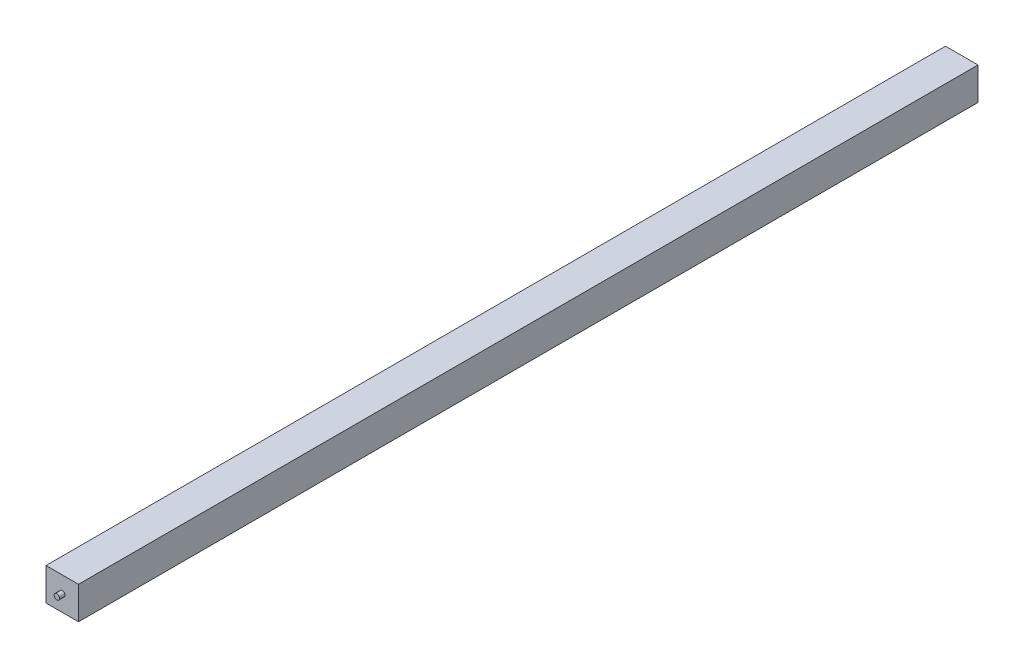
from build123d import *

# Parameters (mm, degrees)
SKETCH1_W           = 830
SKETCH1_H           = 30
BOSS_EXTRUDE1_DEPTH = 15
SKETCH3_R           = 2.5
BOSS_EXTRUDE2_DEPTH = 5
SKETCH4_R           = 2.5
BOSS_EXTRUDE3_DEPTH = 5


with BuildPart() as part:
    # Sketch1 → Boss-Extrude1 (new body, symmetric)
    with BuildSketch(Plane(origin=(0, 0, 0), x_dir=(0, 0, -1), z_dir=(1, 0, 0))):
        with Locations((415, 15)):
            Rectangle(SKETCH1_W, SKETCH1_H)
    extrude(amount=BOSS_EXTRUDE1_DEPTH, both=True)

    # Sketch3 → Boss-Extrude2 (add, symmetric)
    with BuildSketch(Plane(origin=(0, 0, -830), x_dir=(-1, 0, 0), z_dir=(0, 0, -1))):
        with Locations((0, 15)):
            Circle(SKETCH3_R)
    extrude(amount=BOSS_EXTRUDE2_DEPTH, both=True)

    # Sketch4 → Boss-Extrude3 (add, symmetric)
    with BuildSketch(Plane.XY):
        with Locations((0, 15)):
            Circle(SKETCH4_R)
    extrude(amount=BOSS_EXTRUDE3_DEPTH, both=True)


solid = part.part
